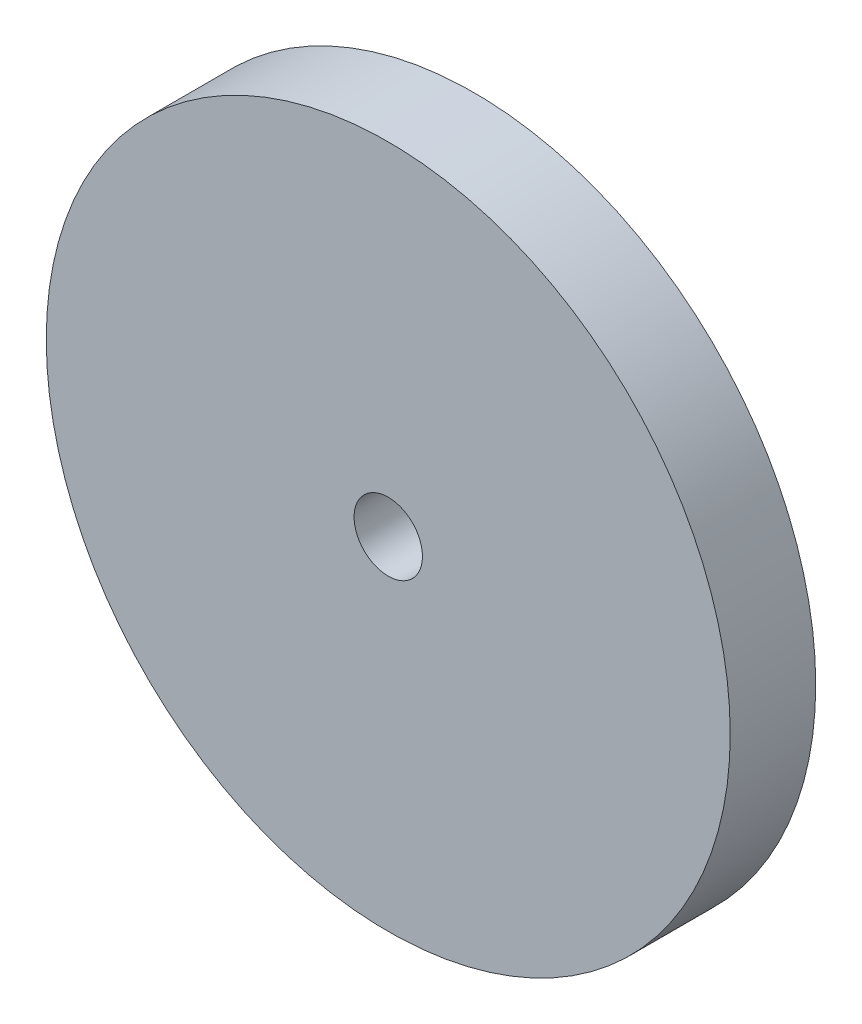
from build123d import *

# Parameters (mm, degrees)
SKETCH1_R           = 12.7
SKETCH1_R_2         = 1.27
BOSS_EXTRUDE1_DEPTH = 3.175


with BuildPart() as part:
    # Sketch1 → Boss-Extrude1 (new body)
    with BuildSketch(Plane.XY):
        Circle(SKETCH1_R)
        Circle(SKETCH1_R_2, mode=Mode.SUBTRACT)
    extrude(amount=BOSS_EXTRUDE1_DEPTH)


solid = part.part
